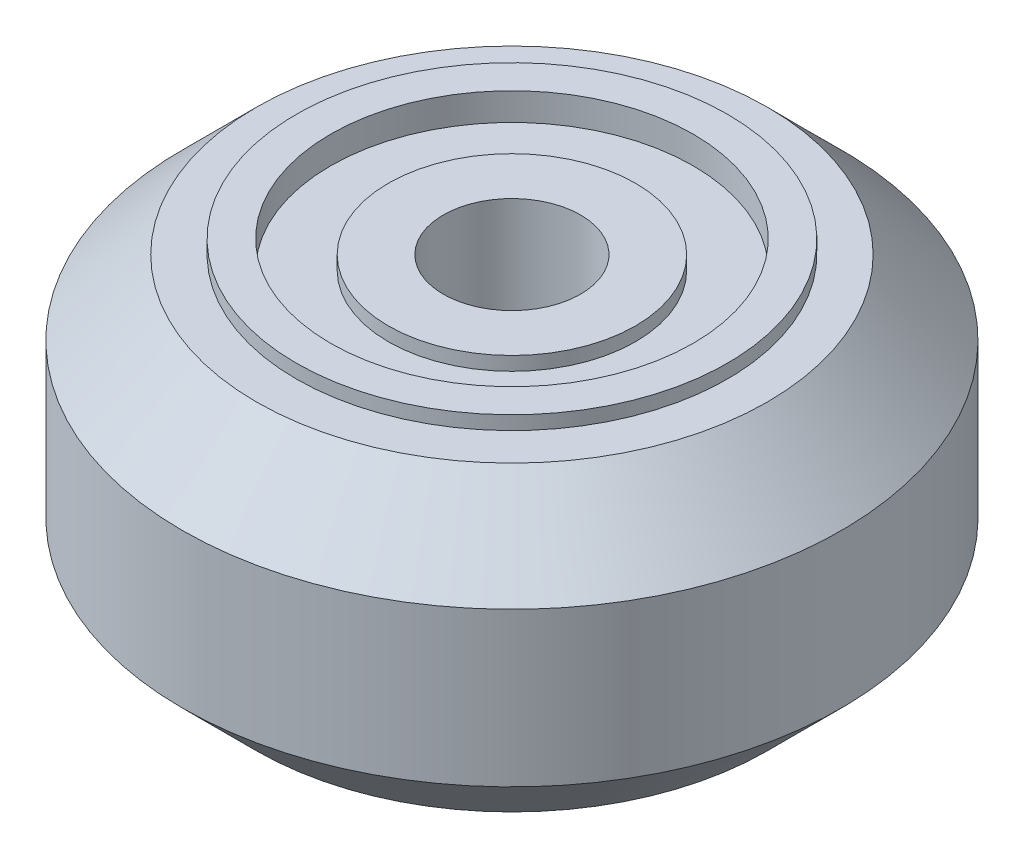
from build123d import *

# Parameters (mm, degrees)
SKETCH1_R                = 12
BOSS_EXTRUDE1_DEPTH      = 11
CHAMFER1_SIZE            = 2.7
SKETCH2_R                = 2.5
CUT_EXTRUDE1_DEPTH       = 21.223748416
BOSS_EXTRUDE4_DEPTH      = 0.5
BOSS_EXTRUDE4_DEPTH_BACK = 11.5
SKETCH3_R                = 7.85
SKETCH3_R_2              = 6.6
SKETCH3_4_R              = 6.6
SKETCH3_4_R_2            = 4.5
CUT_EXTRUDE2_DEPTH       = 0.5
CUT_EXTRUDE3_START       = -10.5
SKETCH3_5_R              = 6.6
SKETCH3_5_R_2            = 4.5
CUT_EXTRUDE3_DEPTH       = 0.5


with BuildPart() as part:
    # Sketch1 → Boss-Extrude1 (new body)
    with BuildSketch(Plane(origin=(0, 0, 0), x_dir=(1, 0, 0), z_dir=(0, 1, 0))):
        Circle(SKETCH1_R)
    extrude(amount=BOSS_EXTRUDE1_DEPTH)

    # Chamfer1
    chamfer1_edges = [part.edges().sort_by_distance(p)[0] for p in [
        (-12, 0, 0),
        (-12, 11, 0),
    ]]
    chamfer(chamfer1_edges, length=CHAMFER1_SIZE)

    # Sketch2 → Cut-Extrude1 (cut, through all)
    with BuildSketch(Plane.XZ):
        Circle(SKETCH2_R)
    extrude(amount=-CUT_EXTRUDE1_DEPTH, mode=Mode.SUBTRACT)

    # Sketch3 → Boss-Extrude4 (add, two sides: drawn at the far end of the back side and taken through both)
    with BuildSketch(Plane.XZ.offset(-BOSS_EXTRUDE4_DEPTH_BACK)):
        Circle(SKETCH3_R)
        Circle(SKETCH3_R_2, mode=Mode.SUBTRACT)
    extrude(amount=BOSS_EXTRUDE4_DEPTH + BOSS_EXTRUDE4_DEPTH_BACK)

    # Sketch3_4 → Cut-Extrude2 (cut)
    with BuildSketch(Plane.XZ):
        Circle(SKETCH3_4_R)
        Circle(SKETCH3_4_R_2, mode=Mode.SUBTRACT)
    extrude(amount=-CUT_EXTRUDE2_DEPTH, mode=Mode.SUBTRACT)

    # Sketch3_5 → Cut-Extrude3 (cut)
    with BuildSketch(Plane.XZ.offset(CUT_EXTRUDE3_START)):
        Circle(SKETCH3_5_R)
        Circle(SKETCH3_5_R_2, mode=Mode.SUBTRACT)
    extrude(amount=-CUT_EXTRUDE3_DEPTH, mode=Mode.SUBTRACT)


solid = part.part
